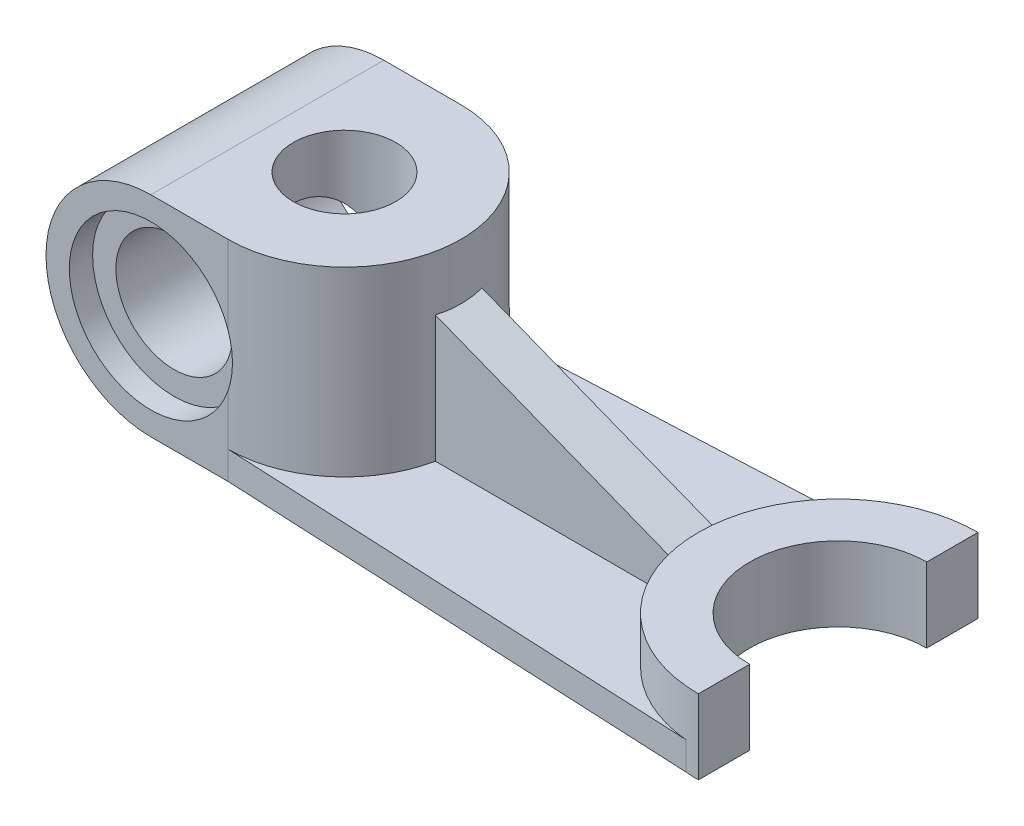
from build123d import *

# Parameters (mm, degrees)
BOSS_EXTRUDE1_DEPTH = 16
SKETCH4_R           = 11
BOSS_EXTRUDE5_DEPTH = 45
SKETCH8_R           = 12.5
BOSS_EXTRUDE8_DEPTH = 50
SKETCH11_R          = 12.5
CUT_EXTRUDE1_DEPTH  = 50
SKETCH12_R          = 17.5
CUT_EXTRUDE2_DEPTH  = 5
BOSS_EXTRUDE9_DEPTH = 6
RIB4_REACH          = 156.758
SKETCH16_WALL_W     = 366.24251427
SKETCH16_WALL_H     = 10


with BuildPart() as part:
    # Sketch2 → Boss-Extrude1 (new body)
    with BuildSketch(Plane(origin=(0, 0, 0), x_dir=(1, 0, 0), z_dir=(0, 1, 0))):
        with BuildLine():
            Line((0, 19), (0, 30))
            ThreePointArc((0, 30), (-30, 0), (0, -30))
            Line((0, -30), (0, -19))
            ThreePointArc((0, -19), (-19, 0), (0, 19))
        make_face()
    extrude(amount=BOSS_EXTRUDE1_DEPTH)



with BuildPart() as body_2:
    # Sketch4 → Boss-Extrude5 (new body)
    with BuildSketch(Plane(origin=(0, 0, 0), x_dir=(1, 0, 0), z_dir=(0, 1, 0))):
        with BuildLine():
            Line((-122.5, 25), (-105.941325388, 25))
            ThreePointArc((-105.941325388, 25), (-80.941325388, 0), (-105.941325388, -25))
            Line((-105.941325388, -25), (-122.5, -25))
            Line((-122.5, -25), (-122.5, 25))
        make_face()
        with Locations(Location((-105.941325388, 0, 0), (0, 0, 90))):
            Circle(SKETCH4_R, mode=Mode.SUBTRACT)
    extrude(amount=BOSS_EXTRUDE5_DEPTH)

    # Sketch8 → Boss-Extrude8 (add)
    with BuildSketch(Plane.XY.offset(25)):
        with Locations((-122.5, 22.5)):
            Circle(SKETCH8_R)
        with BuildLine():
            ThreePointArc((-122.5, 45), (-145, 22.5), (-122.5, 0))
            Line((-122.5, 0), (-122.5, 45))
        make_face()
        with BuildLine():
            ThreePointArc((-122.5, 35), (-135, 22.5), (-122.5, 10))
            Line((-122.5, 10), (-122.5, 35))
        make_face()
        with BuildLine():
            Line((-122.5, 35), (-122.5, 10))
            ThreePointArc((-122.5, 10), (-113.661165235, 13.661165235), (-110, 22.5))
            ThreePointArc((-110, 22.5), (-113.661165235, 31.338834765), (-122.5, 35))
        make_face()
    extrude(amount=-BOSS_EXTRUDE8_DEPTH)

    # Sketch11 → Cut-Extrude1 (cut)
    with BuildSketch(Plane.XY.offset(25)):
        with Locations((-122.5, 22.5)):
            Circle(SKETCH11_R)
    extrude(amount=-CUT_EXTRUDE1_DEPTH, mode=Mode.SUBTRACT)

    # Sketch12 → Cut-Extrude2 (cut)
    with BuildSketch(Plane.XY.offset(25)):
        with Locations((-122.5, 22.5)):
            Circle(SKETCH12_R)
    extrude(amount=-CUT_EXTRUDE2_DEPTH, mode=Mode.SUBTRACT)


with BuildPart() as part_1:
    add(part.part)

    add(body_2.part)  # Boss-Extrude9 merges body 2
    # Sketch13 → Boss-Extrude9 (add)
    with BuildSketch(Plane(origin=(0, 0, 0), x_dir=(1, 0, 0), z_dir=(0, 1, 0))):
        with BuildLine():
            ThreePointArc((-105.941325388, 25), (-80.941325388, 0), (-105.941325388, -25))
            Line((-105.941325388, -25), (-2.825462558, -29.86664965))
            ThreePointArc((-2.825462558, -29.86664965), (-30, 0), (-2.825462558, 29.86664965))
            Line((-2.825462558, 29.86664965), (-105.941325388, 25))
        make_face()
    extrude(amount=BOSS_EXTRUDE9_DEPTH)

    # Sketch16 wall → Rib4 (add, up to next)
    with BuildSketch(Plane(origin=(-55.470662694, 23, 0), x_dir=(0.930830223145, -0.365451906112, 0), z_dir=(0.365451906112, 0.930830223145, 0)), mode=Mode.PRIVATE) as rib4_sk1:
        Rectangle(SKETCH16_WALL_W, SKETCH16_WALL_H)
    rib4_tool1 = extrude(rib4_sk1.sketch, amount=-RIB4_REACH, mode=Mode.PRIVATE) - part_1.part
    add(rib4_tool1.solids().sort_by_distance((-55.470662694, 23, 0))[0])


solid = part_1.part
